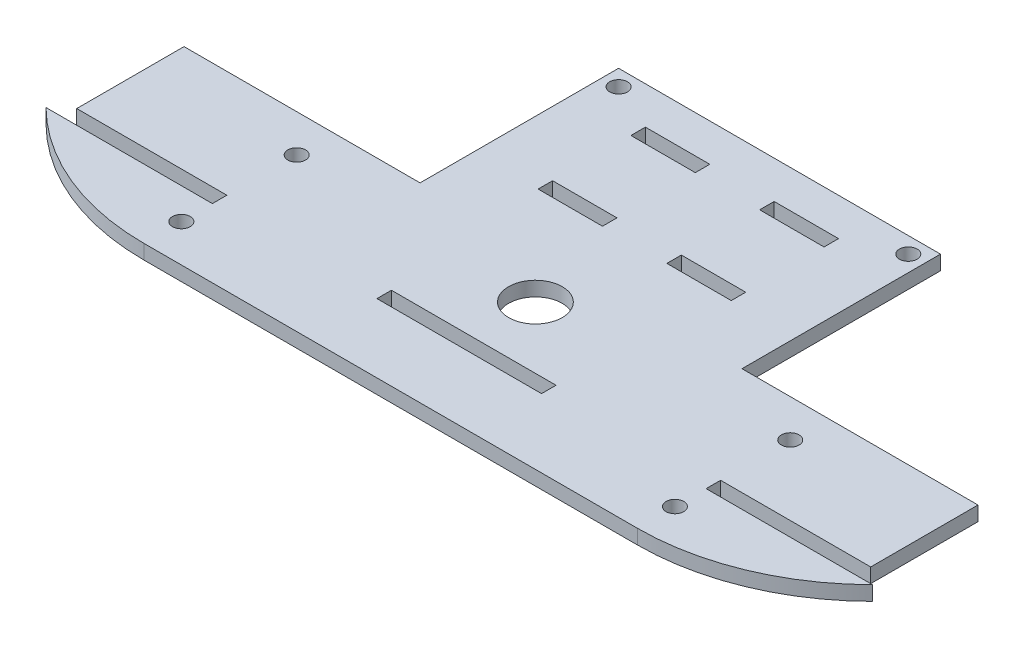
from build123d import *

# Parameters (mm, degrees)
SKETCH1_R           = 1.65
SKETCH1_R_2         = 5
SKETCH1_W           = 30.68
SKETCH1_H           = 2.7
SKETCH1_W_2         = 12
BOSS_EXTRUDE1_DEPTH = 2.7


with BuildPart() as part:
    # Sketch1 → Boss-Extrude1 (new body)
    with BuildSketch(Plane(origin=(0, 0, 0), x_dir=(1, 0, 0), z_dir=(0, 1, 0))):
        with BuildLine():
            Line((-46, 0), (46, 0))
            ThreePointArc((46, 0), (62.780941571, 3.32568378), (77.025151087, 12.8))
            Line((77.025151087, 12.8), (46.015151087, 12.8))
            Line((46.015151087, 12.8), (46.015151087, 15.5))
            Line((46.015151087, 15.5), (73.995151087, 15.5))
            Line((73.995151087, 15.5), (73.995151087, 35.5))
            Line((73.995151087, 35.5), (30, 35.5))
            Line((30, 35.5), (30, 70.5))
            Line((30, 70.5), (30, 72.5))
            Line((30, 72.5), (-30, 72.5))
            Line((-30, 72.5), (-30, 70.5))
            Line((-30, 70.5), (-30, 35.5))
            Line((-30, 35.5), (-73.995151087, 35.5))
            Line((-73.995151087, 35.5), (-73.995151087, 15.5))
            Line((-73.995151087, 15.5), (-46.015151087, 15.5))
            Line((-46.015151087, 15.5), (-46.015151087, 12.8))
            Line((-46.015151087, 12.8), (-77.025151087, 12.8))
            ThreePointArc((-77.025151087, 12.8), (-62.780941571, 3.32568378), (-46, 0))
        make_face()
        with Locations((46, 28.5)):
            Circle(SKETCH1_R, mode=Mode.SUBTRACT)
        with Locations((46, 7)):
            Circle(SKETCH1_R, mode=Mode.SUBTRACT)
        with Locations((-46, 7)):
            Circle(SKETCH1_R, mode=Mode.SUBTRACT)
        with Locations((-46, 28.5)):
            Circle(SKETCH1_R, mode=Mode.SUBTRACT)
        with Locations((-27, 69.5)):
            Circle(SKETCH1_R, mode=Mode.SUBTRACT)
        with Locations((27, 69.5)):
            Circle(SKETCH1_R, mode=Mode.SUBTRACT)
        with Locations((0, 27)):
            Circle(SKETCH1_R_2, mode=Mode.SUBTRACT)
        with Locations((0, 14.15)):
            Rectangle(SKETCH1_W, SKETCH1_H, mode=Mode.SUBTRACT)
        with Locations((12, 46.85)):
            Rectangle(SKETCH1_W_2, SKETCH1_H, mode=Mode.SUBTRACT)
        with Locations((-12, 64.15)):
            Rectangle(SKETCH1_W_2, SKETCH1_H, mode=Mode.SUBTRACT)
        with Locations((12, 64.15)):
            Rectangle(SKETCH1_W_2, SKETCH1_H, mode=Mode.SUBTRACT)
        with Locations((-12, 46.85)):
            Rectangle(SKETCH1_W_2, SKETCH1_H, mode=Mode.SUBTRACT)
    extrude(amount=BOSS_EXTRUDE1_DEPTH)


solid = part.part
